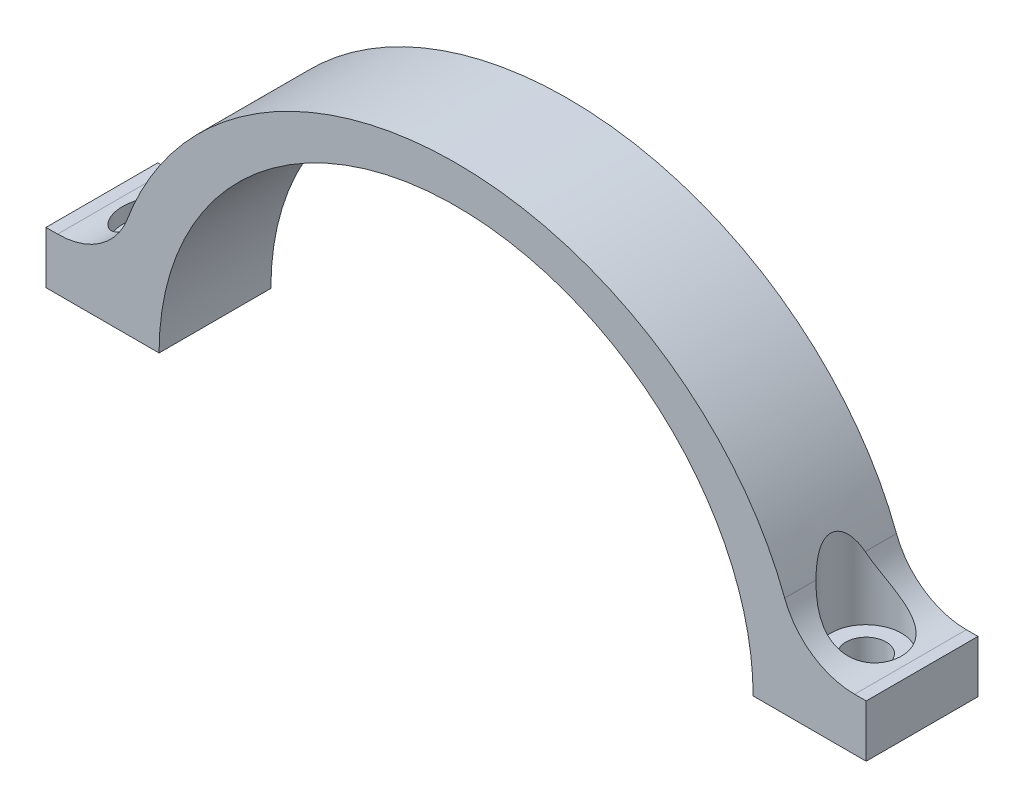
from build123d import *

# Parameters (mm, degrees)
BOSS_EXTRUDE1_DEPTH     = 15
FILLET1_R               = 10
SKETCH3_R               = 2.7
CUT_EXTRUDE1_DEPTH      = 17
CUT_EXTRUDE2_DEPTH      = 12
CUT_EXTRUDE2_DEPTH_BACK = 1
SKETCH3_4_R             = 2.7
SKETCH5_R               = 4.75
CUT_EXTRUDE3_DEPTH      = 17


with BuildPart() as part:
    # Sketch1 → Boss-Extrude1 (new body)
    with BuildSketch(Plane.XY):
        with BuildLine():
            Line((-39.855, 0), (-55.024390244, 0))
            Line((-55.024390244, 0), (-55.024390244, 7.011281463))
            Line((-55.024390244, 7.011281463), (-45.900914662, 6.989739898))
            add(Edge.make_bspline(
                [(45.900914662, 6.989739898), (39.351881023, 42), (0, 42), (-39.351881023, 42), (-45.900914662, 6.989739898)],
                knots=[3.308792985, 3.308792985, 3.308792985, 4.71238898, 4.71238898, 6.115984976, 6.115984976, 6.115984976], degree=2, weights=[1, 0.76368265, 1, 0.76368265, 1]))
            Line((45.900914662, 6.989739898), (55.024390244, 7.011281463))
            Line((55.024390244, 7.011281463), (55.024390244, 0))
            Line((55.024390244, 0), (39.855, 0))
            add(Edge.make_bspline(
                [(39.855, 0), (39.855, 37), (0, 37), (-39.855, 37), (-39.855, 0)],
                knots=[0, 0, 0, 1.570796327, 1.570796327, 3.141592654, 3.141592654, 3.141592654], degree=2, weights=[1, 0.707106781, 1, 0.707106781, 1]))
        make_face()
    extrude(amount=BOSS_EXTRUDE1_DEPTH)

    # Fillet1
    fillet1_edges = [part.edges().sort_by_distance(p)[0] for p in [
        (45.900914662, 6.989739898, 7.5),
        (-45.900914662, 6.989739898, 7.5),
    ]]
    fillet(fillet1_edges, radius=FILLET1_R)

    # Sketch3 → Cut-Extrude1 (cut)
    with BuildSketch(Plane(origin=(0, 0, 0), x_dir=(1, 0, 0), z_dir=(0, 1, 0))):
        with Locations((-47.5, -7.5)):
            Circle(SKETCH3_R)
    extrude(amount=CUT_EXTRUDE1_DEPTH, mode=Mode.SUBTRACT)

    # Sketch3_4 → Cut-Extrude2 (cut, two sides: drawn at the far end of the back side and taken through both)
    with BuildSketch(Plane(origin=(0, 0, 0), x_dir=(1, 0, 0), z_dir=(0, 1, 0)).offset(-CUT_EXTRUDE2_DEPTH_BACK)):
        with Locations((47.5, -7.5)):
            Circle(SKETCH3_4_R)
        with Locations((-47.5, -7.5)):
            Circle(SKETCH3_4_R)
    extrude(amount=CUT_EXTRUDE2_DEPTH + CUT_EXTRUDE2_DEPTH_BACK, mode=Mode.SUBTRACT)

    # Sketch5 → Cut-Extrude3 (cut)
    with BuildSketch(Plane(origin=(0, 5, 0), x_dir=(1, 0, 0), z_dir=(0, 1, 0))):
        with Locations((-47.5, -7.5)):
            Circle(SKETCH5_R)
        with Locations((47.5, -7.5)):
            Circle(SKETCH5_R)
    extrude(amount=CUT_EXTRUDE3_DEPTH, mode=Mode.SUBTRACT)


solid = part.part
